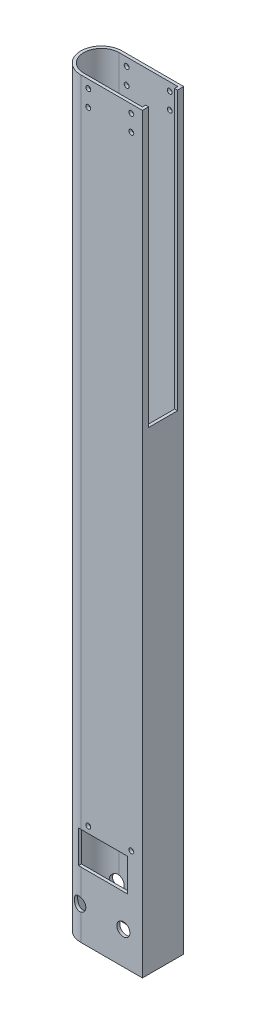
from build123d import *

# Parameters (mm, degrees)
AUFSATZ_LINEAR_START                        = 170
AUFSATZ_LINEAR_AUSTRAGEN2_DEPTH             = 460
SCHNITT_LINEAR_AUSTRAGEN1_REACH             = 14.65
SKIZZE15_R                                  = 4
SCHNITT_LINEAR_AUSTRAGEN1_DIRECTION_2_REACH = 14.65
SKIZZE17_W                                  = 30
SKIZZE17_H                                  = 20
SCHNITT_LINEAR_AUSTRAGEN2_DEPTH             = 12.65
SKIZZE19_W                                  = 17.7
SKIZZE19_H                                  = 170
SCHNITT_LINEAR_AUSTRAGEN3_DEPTH             = 25.15
HOLES_R                                     = 1.5
SCHNITT_LINEAR_AUSTRAGEN5_DEPTH             = 13.6500001
SCHNITT_LINEAR_AUSTRAGEN5_DEPTH_BACK        = 13.6500001
SKIZZE23_R                                  = 1.5
SCHNITT_LINEAR_AUSTRAGEN7_DEPTH             = 13.6500001
SCHNITT_LINEAR_AUSTRAGEN7_DEPTH_BACK        = 13.6500001


with BuildPart() as part:
    # Skizze10 (on Top Plane) → Aufsatz-Linear austragen2 (new body)
    with BuildSketch(Plane(origin=(0, 0, 0), x_dir=(1, 0, 0), z_dir=(0, 1, 0)).offset(AUFSATZ_LINEAR_START)):
        with BuildLine():
            Line((25.15, 12.65), (-12.6, 12.65))
            ThreePointArc((-12.6, 12.65), (-25.25, 0), (-12.6, -12.65))
            Line((-12.6, -12.65), (25.15, -12.65))
            Line((25.15, -12.65), (25.15, 12.65))
        make_face()
        with BuildLine():
            Line((23.35, 10.85), (-12.6, 10.85))
            ThreePointArc((-12.6, 10.85), (-23.45, 0), (-12.6, -10.85))
            Line((-12.6, -10.85), (23.35, -10.85))
            Line((23.35, -10.85), (23.35, 10.85))
        make_face(mode=Mode.SUBTRACT)
    extrude(amount=AUFSATZ_LINEAR_AUSTRAGEN2_DEPTH)

    # Schnitt-Linear austragen1: up to this face of the body (flat: up to its plane)
    schnitt_linear_austragen1_end = Plane(part.part.faces().sort_by_distance((6.275, 400, -12.65))[0])
    # Skizze15 → Schnitt-Linear austragen1 (cut, up to the picked face)
    with BuildSketch(Plane.XY, mode=Mode.PRIVATE) as schnitt_linear_austragen1_sk1:
        with Locations((-13.5, 190)):
            Circle(SKIZZE15_R)
    schnitt_linear_austragen1_tool1 = split(extrude(schnitt_linear_austragen1_sk1.sketch, amount=-SCHNITT_LINEAR_AUSTRAGEN1_REACH, mode=Mode.PRIVATE), bisect_by=schnitt_linear_austragen1_end, keep=Keep.BOTH, mode=Mode.PRIVATE)
    add(schnitt_linear_austragen1_tool1.solids().sort_by_distance((-13.5, 190, 0))[0], mode=Mode.SUBTRACT)
    # Skizze15 → Schnitt-Linear austragen1 (cut, up to the picked face)
    with BuildSketch(Plane.XY, mode=Mode.PRIVATE) as schnitt_linear_austragen1_sk2:
        with Locations((13.5, 190)):
            Circle(SKIZZE15_R)
    schnitt_linear_austragen1_tool2 = split(extrude(schnitt_linear_austragen1_sk2.sketch, amount=-SCHNITT_LINEAR_AUSTRAGEN1_REACH, mode=Mode.PRIVATE), bisect_by=schnitt_linear_austragen1_end, keep=Keep.BOTH, mode=Mode.PRIVATE)
    add(schnitt_linear_austragen1_tool2.solids().sort_by_distance((13.5, 190, 0))[0], mode=Mode.SUBTRACT)

    # Schnitt-Linear austragen1 direction 2: up to this face of the body (flat: up to its plane)
    schnitt_linear_austragen1_direction_2_end = Plane(part.part.faces().sort_by_distance((6.275, 400, 12.65))[0])
    # Skizze15 → Schnitt-Linear austragen1 direction 2 (cut, up to the picked face)
    with BuildSketch(Plane.XY, mode=Mode.PRIVATE) as schnitt_linear_austragen1_direction_2_sk1:
        with Locations((-13.5, 190)):
            Circle(SKIZZE15_R)
    schnitt_linear_austragen1_direction_2_tool1 = split(extrude(schnitt_linear_austragen1_direction_2_sk1.sketch, amount=SCHNITT_LINEAR_AUSTRAGEN1_DIRECTION_2_REACH, mode=Mode.PRIVATE), bisect_by=schnitt_linear_austragen1_direction_2_end, keep=Keep.BOTH, mode=Mode.PRIVATE)
    add(schnitt_linear_austragen1_direction_2_tool1.solids().sort_by_distance((-13.5, 190, 0))[0], mode=Mode.SUBTRACT)
    # Skizze15 → Schnitt-Linear austragen1 direction 2 (cut, up to the picked face)
    with BuildSketch(Plane.XY, mode=Mode.PRIVATE) as schnitt_linear_austragen1_direction_2_sk2:
        with Locations((13.5, 190)):
            Circle(SKIZZE15_R)
    schnitt_linear_austragen1_direction_2_tool2 = split(extrude(schnitt_linear_austragen1_direction_2_sk2.sketch, amount=SCHNITT_LINEAR_AUSTRAGEN1_DIRECTION_2_REACH, mode=Mode.PRIVATE), bisect_by=schnitt_linear_austragen1_direction_2_end, keep=Keep.BOTH, mode=Mode.PRIVATE)
    add(schnitt_linear_austragen1_direction_2_tool2.solids().sort_by_distance((13.5, 190, 0))[0], mode=Mode.SUBTRACT)

    # Skizze17 → Schnitt-Linear austragen2 (cut)
    with BuildSketch(Plane.XY):
        with Locations((1, 220)):
            Rectangle(SKIZZE17_W, SKIZZE17_H)
    extrude(amount=SCHNITT_LINEAR_AUSTRAGEN2_DEPTH, mode=Mode.SUBTRACT)

    # Skizze19 → Schnitt-Linear austragen3 (cut)
    with BuildSketch(Plane(origin=(0, 0, 0), x_dir=(0, 0, -1), z_dir=(1, 0, 0))):
        with Locations((0, 545)):
            Rectangle(SKIZZE19_W, SKIZZE19_H)
    extrude(amount=SCHNITT_LINEAR_AUSTRAGEN3_DEPTH, mode=Mode.SUBTRACT)

    # Holes → Schnitt-Linear austragen5 (cut, two sides)
    with BuildSketch(Plane.XY) as schnitt_linear_austragen5_sk:
        with Locations((18.35, 615)):
            Circle(HOLES_R)
        with Locations((-8, 615)):
            Circle(HOLES_R)
        with Locations((18.35, 234)):
            Circle(HOLES_R)
        with Locations((-8, 234)):
            Circle(HOLES_R)
    extrude(amount=SCHNITT_LINEAR_AUSTRAGEN5_DEPTH, mode=Mode.SUBTRACT)
    extrude(schnitt_linear_austragen5_sk.sketch, amount=-SCHNITT_LINEAR_AUSTRAGEN5_DEPTH_BACK, mode=Mode.SUBTRACT)

    # Skizze23 → Schnitt-Linear austragen7 (cut, two sides)
    with BuildSketch(Plane.XY) as schnitt_linear_austragen7_sk:
        with Locations((-8, 625)):
            Circle(SKIZZE23_R)
        with Locations((18.35, 625)):
            Circle(SKIZZE23_R)
    extrude(amount=SCHNITT_LINEAR_AUSTRAGEN7_DEPTH, mode=Mode.SUBTRACT)
    extrude(schnitt_linear_austragen7_sk.sketch, amount=-SCHNITT_LINEAR_AUSTRAGEN7_DEPTH_BACK, mode=Mode.SUBTRACT)


solid = part.part
